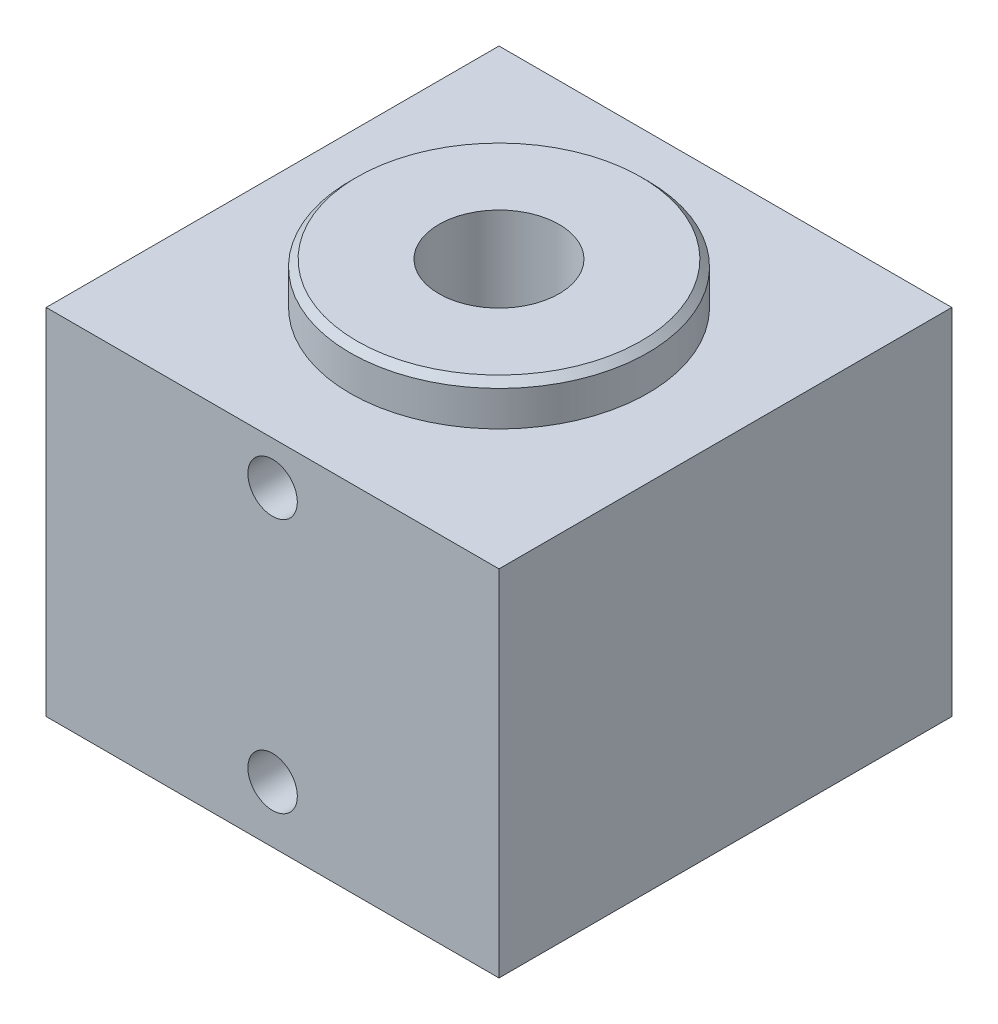
from build123d import *

# Parameters (mm, degrees)
SKETCH1_W          = 101.6
SKETCH1_H          = 101.6
EXTRUDE1_DEPTH     = 79.502
SKETCH2_R          = 33.401
EXTRUDE2_DEPTH     = 9.398
CHAMFER1_SIZE      = 1.524
SKETCH3_R          = 13.4874
CUT_EXTRUDE1_DEPTH = 89.9
SKETCH4_R          = 5.5499
CUT_EXTRUDE2_DEPTH = 12.7
HOLE1_D            = 7.9375
HOLE1_DEPTH        = 12.7


with BuildPart() as part:
    # Sketch1 → Extrude1 (new body)
    with BuildSketch(Plane(origin=(0, 0, 0), x_dir=(1, 0, 0), z_dir=(0, 1, 0))):
        Rectangle(SKETCH1_W, SKETCH1_H)
    extrude(amount=EXTRUDE1_DEPTH)

    # Sketch2 → Extrude2 (add)
    with BuildSketch(Plane(origin=(0, 79.502, 0), x_dir=(-1, 0, 0), z_dir=(0, 1, 0))):
        with Locations(Location((0, 0, 0), (0, 0, 90))):  # turned: the seam where the file's is
            Circle(SKETCH2_R)
    extrude(amount=EXTRUDE2_DEPTH)

    # Chamfer1
    chamfer1_edges = [part.edges().sort_by_distance(p)[0] for p in [
        (0, 88.9, -33.401),
    ]]
    chamfer(chamfer1_edges, length=CHAMFER1_SIZE)

    # Sketch3 → Cut-Extrude1 (cut, through all)
    with BuildSketch(Plane(origin=(0, 88.9, 0), x_dir=(1, 0, 0), z_dir=(0, 1, 0))):
        with Locations(Location((0, 0, 0), (0, 0, 270))):  # turned: the seam where the file's is
            Circle(SKETCH3_R)
    extrude(amount=-CUT_EXTRUDE1_DEPTH, mode=Mode.SUBTRACT)

    # Sketch4 → Cut-Extrude2 (cut)
    with BuildSketch(Plane.XY.offset(50.8)):
        with Locations((0, 69.85)):
            Circle(SKETCH4_R)
        with Locations((0, 12.7)):
            Circle(SKETCH4_R)
    extrude(amount=-CUT_EXTRUDE2_DEPTH, mode=Mode.SUBTRACT)

    # Hole1
    with Locations(Plane.XZ):
        with Locations((-38.1, 38.1), (38.1, 38.1), (38.1, -38.1), (-38.1, -38.1)):
            Hole(HOLE1_D / 2, depth=HOLE1_DEPTH)


solid = part.part
